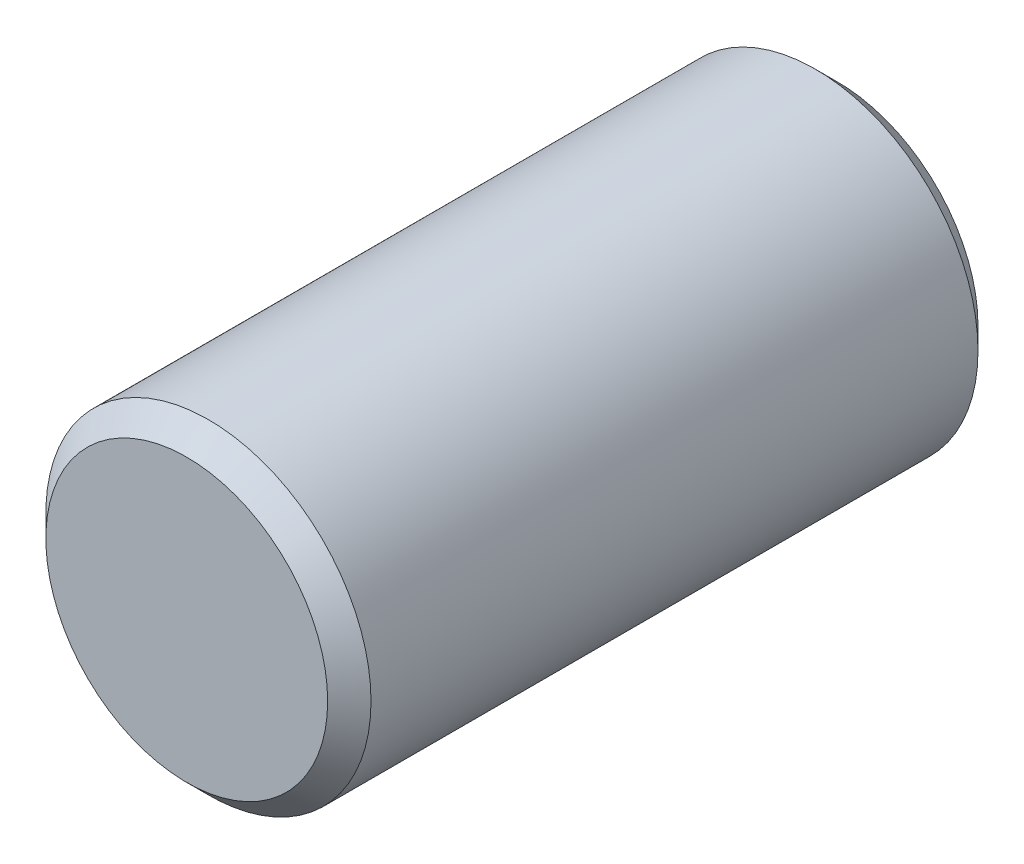
from build123d import *

# Parameters (mm, degrees)
SKETCH1_R           = 0.375
BOSS_EXTRUDE1_DEPTH = 0.75
CHAMFER1_SIZE       = 0.05


with BuildPart() as part:
    # Sketch1 → Boss-Extrude1 (new body, symmetric)
    with BuildSketch(Plane.XY):
        Circle(SKETCH1_R)
    extrude(amount=BOSS_EXTRUDE1_DEPTH, both=True)

    # Chamfer1
    chamfer1_edges = [part.edges().sort_by_distance(p)[0] for p in [
        (-0.375, 0, -0.75),
        (-0.375, 0, 0.75),
    ]]
    chamfer(chamfer1_edges, length=CHAMFER1_SIZE)


solid = part.part
